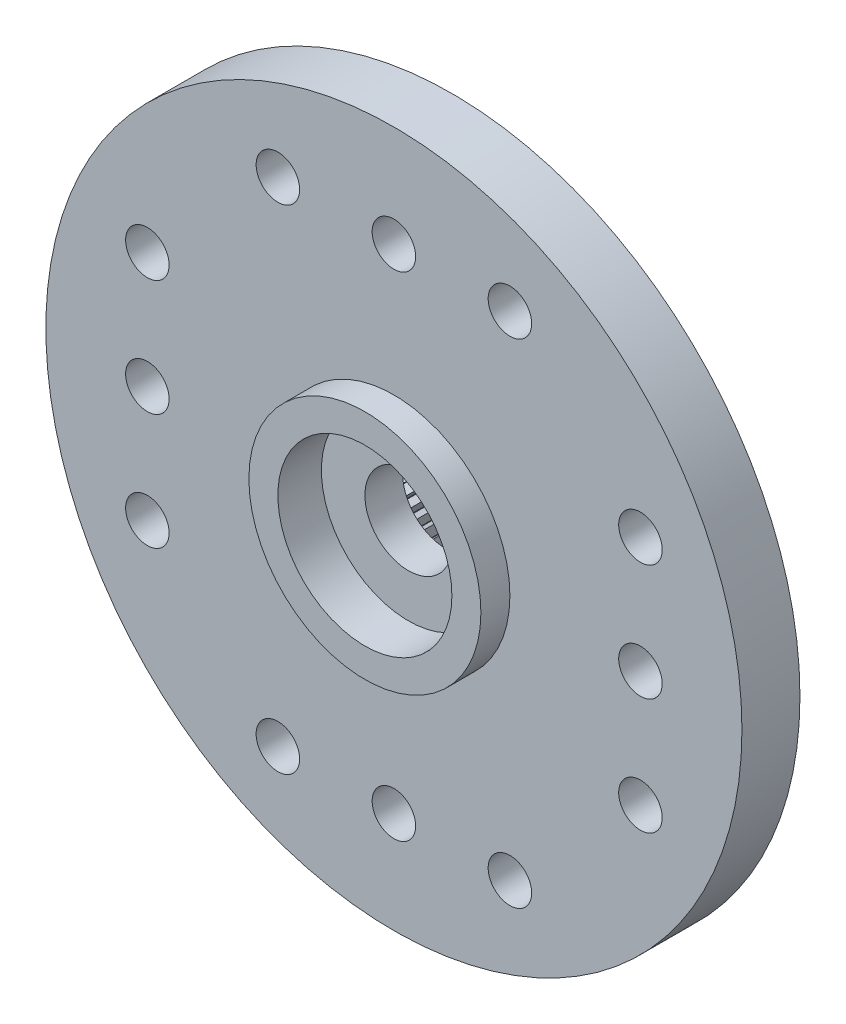
from build123d import *

# Parameters (mm, degrees)
ESQUISSE1_R                     = 4.5
BOSS_EXTRU_1_DEPTH              = 3.5
ESQUISSE2_R                     = 12
BOSS_EXTRU_2_DEPTH              = 2
ESQUISSE5_R                     = 4
BOSS_EXTRU_3_DEPTH              = 1
DIAM_TRE_DU_PER_AGE_3_0_3_2_D   = 3
ESQUISSE8_R                     = 3
ENL_V_MAT_EXTRU_1_DEPTH         = 1.5
ENL_V_MAT_EXTRU_2_DEPTH         = 3.7
DIAM_TRE_DU_PER_AGE_1_5_1_5_1_D = 1.5
R_P_TITION_CIRCULAIRE1_COUNT    = 4


with BuildPart() as part:
    # Esquisse1 → Boss.-Extru.1 (new body)
    with BuildSketch(Plane.XY):
        Circle(ESQUISSE1_R)
    extrude(amount=BOSS_EXTRU_1_DEPTH)

    # Esquisse2 → Boss.-Extru.2 (add)
    with BuildSketch(Plane.XY.offset(3.5)):
        Circle(ESQUISSE2_R)
    extrude(amount=BOSS_EXTRU_2_DEPTH)

    # Esquisse5 → Boss.-Extru.3 (add)
    with BuildSketch(Plane.XY.offset(5.5)):
        Circle(ESQUISSE5_R)
    extrude(amount=BOSS_EXTRU_3_DEPTH)

    # Diamètre du perçage Ø3.0 (3)2 (through all)
    with Locations(Plane.XY.offset(6.5)):
        with Locations((0, 0)):
            Hole(DIAM_TRE_DU_PER_AGE_3_0_3_2_D / 2)

    # Esquisse8 → Enlèv. mat.-Extru.1 (cut)
    with BuildSketch(Plane.XY.offset(6.5)):
        Circle(ESQUISSE8_R)
    extrude(amount=-ENL_V_MAT_EXTRU_1_DEPTH, mode=Mode.SUBTRACT)

    # Esquisse9 → Enlèv. mat.-Extru.2 (cut)
    with BuildSketch(Plane(origin=(0, 0, 0), x_dir=(-1, 0, 0), z_dir=(0, 0, -1))):
        with BuildLine():
            Line((0, 2.5), (0.180017522, 2.994594078))
            ThreePointArc((0.180017522, 2.994594078), (0.188371559, 2.994080185), (0.196724129, 2.993542987))
            Line((0.196724129, 2.993542987), (0.313333084, 2.480286753))
            Line((0.313333084, 2.480286753), (0.553920189, 2.948418631))
            ThreePointArc((0.553920189, 2.948418631), (0.562143944, 2.946861752), (0.570363322, 2.945281936))
            Line((0.570363322, 2.945281936), (0.621724718, 2.421457903))
            Line((0.621724718, 2.421457903), (0.919087204, 2.855744861))
            ThreePointArc((0.919087204, 2.855744861), (0.927050983, 2.853169549), (0.935007546, 2.850572028))
            Line((0.935007546, 2.850572028), (0.920311382, 2.324441215))
            Line((0.920311382, 2.324441215), (1.269759665, 2.718034289))
            ThreePointArc((1.269759665, 2.718034289), (1.277337875, 2.714481157), (1.284906142, 2.710906897))
            Line((1.284906142, 2.710906897), (1.204384185, 2.1907667))
            Line((1.204384185, 2.1907667), (1.600407257, 2.537458692))
            ThreePointArc((1.600407257, 2.537458692), (1.607480385, 2.532983777), (1.614541001, 2.528489145))
            Line((1.614541001, 2.528489145), (1.469463131, 2.022542486))
            Line((1.469463131, 2.022542486), (1.905815471, 2.316865855))
            ThreePointArc((1.905815471, 2.316865855), (1.912271969, 2.311539728), (1.918713583, 2.306195609))
            Line((1.918713583, 2.306195609), (1.711367765, 1.822421569))
            Line((1.711367765, 1.822421569), (2.181167836, 2.059734661))
            ThreePointArc((2.181167836, 2.059734661), (2.186905882, 2.053641318), (2.192626906, 2.04753199))
            Line((2.192626906, 2.04753199), (1.926283107, 1.593559974))
            Line((1.926283107, 1.593559974), (2.422121881, 1.77012022))
            ThreePointArc((2.422121881, 1.77012022), (2.427050983, 1.763355757), (2.431961193, 1.756577568))
            Line((2.431961193, 1.756577568), (2.110819814, 1.339566987))
            Line((2.110819814, 1.339566987), (2.624877618, 1.452589926))
            ThreePointArc((2.624877618, 1.452589926), (2.62892004, 1.445261022), (2.632942, 1.437920869))
            Line((2.632942, 1.437920869), (2.262067631, 1.064448229))
            Line((2.262067631, 1.064448229), (2.786237466, 1.112151421))
            ThreePointArc((2.786237466, 1.112151421), (2.789329458, 1.104373658), (2.792399738, 1.096587299))
            Line((2.792399738, 1.096587299), (2.377641291, 0.772542486))
            Line((2.377641291, 0.772542486), (2.903656685, 0.754173624))
            ThreePointArc((2.903656685, 0.754173624), (2.905749483, 0.746069661), (2.907819664, 0.737959892))
            Line((2.907819664, 0.737959892), (2.455718127, 0.468453286))
            Line((2.455718127, 0.468453286), (2.975283504, 0.384302058))
            ThreePointArc((2.975283504, 0.384302058), (2.976344104, 0.375999701), (2.977381537, 0.367694417))
            Line((2.977381537, 0.367694417), (2.495066821, 0.156976299))
            Line((2.495066821, 0.156976299), (2.999988324, 0.008369819))
            ThreePointArc((2.999988324, 0.008369819), (3, 0), (2.999988324, -0.008369819))
            Line((2.999988324, -0.008369819), (2.495066821, -0.156976299))
            Line((2.495066821, -0.156976299), (2.977381537, -0.367694417))
            ThreePointArc((2.977381537, -0.367694417), (2.976344104, -0.375999701), (2.975283504, -0.384302058))
            Line((2.975283504, -0.384302058), (2.455718127, -0.468453286))
            Line((2.455718127, -0.468453286), (2.907819664, -0.737959892))
            ThreePointArc((2.907819664, -0.737959892), (2.905749483, -0.746069661), (2.903656685, -0.754173624))
            Line((2.903656685, -0.754173624), (2.377641291, -0.772542486))
            Line((2.377641291, -0.772542486), (2.792399738, -1.096587299))
            ThreePointArc((2.792399738, -1.096587299), (2.789329458, -1.104373658), (2.786237466, -1.112151421))
            Line((2.786237466, -1.112151421), (2.262067631, -1.064448229))
            Line((2.262067631, -1.064448229), (2.632942, -1.437920869))
            ThreePointArc((2.632942, -1.437920869), (2.62892004, -1.445261022), (2.624877618, -1.452589926))
            Line((2.624877618, -1.452589926), (2.110819814, -1.339566987))
            Line((2.110819814, -1.339566987), (2.431961193, -1.756577568))
            ThreePointArc((2.431961193, -1.756577568), (2.427050983, -1.763355757), (2.422121881, -1.77012022))
            Line((2.422121881, -1.77012022), (1.926283107, -1.593559974))
            Line((1.926283107, -1.593559974), (2.192626906, -2.04753199))
            ThreePointArc((2.192626906, -2.04753199), (2.186905882, -2.053641318), (2.181167836, -2.059734661))
            Line((2.181167836, -2.059734661), (1.711367765, -1.822421569))
            Line((1.711367765, -1.822421569), (1.918713583, -2.306195609))
            ThreePointArc((1.918713583, -2.306195609), (1.912271969, -2.311539728), (1.905815471, -2.316865855))
            Line((1.905815471, -2.316865855), (1.469463131, -2.022542486))
            Line((1.469463131, -2.022542486), (1.614541001, -2.528489145))
            ThreePointArc((1.614541001, -2.528489145), (1.607480385, -2.532983777), (1.600407257, -2.537458692))
            Line((1.600407257, -2.537458692), (1.204384185, -2.1907667))
            Line((1.204384185, -2.1907667), (1.284906142, -2.710906897))
            ThreePointArc((1.284906142, -2.710906897), (1.277337875, -2.714481157), (1.269759665, -2.718034289))
            Line((1.269759665, -2.718034289), (0.920311382, -2.324441215))
            Line((0.920311382, -2.324441215), (0.935007546, -2.850572028))
            ThreePointArc((0.935007546, -2.850572028), (0.927050983, -2.853169549), (0.919087204, -2.855744861))
            Line((0.919087204, -2.855744861), (0.621724718, -2.421457903))
            Line((0.621724718, -2.421457903), (0.570363322, -2.945281936))
            ThreePointArc((0.570363322, -2.945281936), (0.562143944, -2.946861752), (0.553920189, -2.948418631))
            Line((0.553920189, -2.948418631), (0.313333084, -2.480286753))
            Line((0.313333084, -2.480286753), (0.196724129, -2.993542987))
            ThreePointArc((0.196724129, -2.993542987), (0.188371559, -2.994080185), (0.180017522, -2.994594078))
            Line((0.180017522, -2.994594078), (0, -2.5))
            Line((0, -2.5), (-0.180017522, -2.994594078))
            ThreePointArc((-0.180017522, -2.994594078), (-0.188371559, -2.994080185), (-0.196724129, -2.993542987))
            Line((-0.196724129, -2.993542987), (-0.313333084, -2.480286753))
            Line((-0.313333084, -2.480286753), (-0.553920189, -2.948418631))
            ThreePointArc((-0.553920189, -2.948418631), (-0.562143944, -2.946861752), (-0.570363322, -2.945281936))
            Line((-0.570363322, -2.945281936), (-0.621724718, -2.421457903))
            Line((-0.621724718, -2.421457903), (-0.919087204, -2.855744861))
            ThreePointArc((-0.919087204, -2.855744861), (-0.927050983, -2.853169549), (-0.935007546, -2.850572028))
            Line((-0.935007546, -2.850572028), (-0.920311382, -2.324441215))
            Line((-0.920311382, -2.324441215), (-1.269759665, -2.718034289))
            ThreePointArc((-1.269759665, -2.718034289), (-1.277337875, -2.714481157), (-1.284906142, -2.710906897))
            Line((-1.284906142, -2.710906897), (-1.204384185, -2.1907667))
            Line((-1.204384185, -2.1907667), (-1.600407257, -2.537458692))
            ThreePointArc((-1.600407257, -2.537458692), (-1.607480385, -2.532983777), (-1.614541001, -2.528489145))
            Line((-1.614541001, -2.528489145), (-1.469463131, -2.022542486))
            Line((-1.469463131, -2.022542486), (-1.905815471, -2.316865855))
            ThreePointArc((-1.905815471, -2.316865855), (-1.912271969, -2.311539728), (-1.918713583, -2.306195609))
            Line((-1.918713583, -2.306195609), (-1.711367765, -1.822421569))
            Line((-1.711367765, -1.822421569), (-2.181167836, -2.059734661))
            ThreePointArc((-2.181167836, -2.059734661), (-2.186905882, -2.053641318), (-2.192626906, -2.04753199))
            Line((-2.192626906, -2.04753199), (-1.926283107, -1.593559974))
            Line((-1.926283107, -1.593559974), (-2.422121881, -1.77012022))
            ThreePointArc((-2.422121881, -1.77012022), (-2.427050983, -1.763355757), (-2.431961193, -1.756577568))
            Line((-2.431961193, -1.756577568), (-2.110819814, -1.339566987))
            Line((-2.110819814, -1.339566987), (-2.624877618, -1.452589926))
            ThreePointArc((-2.624877618, -1.452589926), (-2.62892004, -1.445261022), (-2.632942, -1.437920869))
            Line((-2.632942, -1.437920869), (-2.262067631, -1.064448229))
            Line((-2.262067631, -1.064448229), (-2.786237466, -1.112151421))
            ThreePointArc((-2.786237466, -1.112151421), (-2.789329458, -1.104373658), (-2.792399738, -1.096587299))
            Line((-2.792399738, -1.096587299), (-2.377641291, -0.772542486))
            Line((-2.377641291, -0.772542486), (-2.903656685, -0.754173624))
            ThreePointArc((-2.903656685, -0.754173624), (-2.905749483, -0.746069661), (-2.907819664, -0.737959892))
            Line((-2.907819664, -0.737959892), (-2.455718127, -0.468453286))
            Line((-2.455718127, -0.468453286), (-2.975283504, -0.384302058))
            ThreePointArc((-2.975283504, -0.384302058), (-2.976344104, -0.375999701), (-2.977381537, -0.367694417))
            Line((-2.977381537, -0.367694417), (-2.495066821, -0.156976299))
            Line((-2.495066821, -0.156976299), (-2.999988324, -0.008369819))
            ThreePointArc((-2.999988324, -0.008369819), (-3, 0), (-2.999988324, 0.008369819))
            Line((-2.999988324, 0.008369819), (-2.495066821, 0.156976299))
            Line((-2.495066821, 0.156976299), (-2.977381537, 0.367694417))
            ThreePointArc((-2.977381537, 0.367694417), (-2.976344104, 0.375999701), (-2.975283504, 0.384302058))
            Line((-2.975283504, 0.384302058), (-2.455718127, 0.468453286))
            Line((-2.455718127, 0.468453286), (-2.907819664, 0.737959892))
            ThreePointArc((-2.907819664, 0.737959892), (-2.905749483, 0.746069661), (-2.903656685, 0.754173624))
            Line((-2.903656685, 0.754173624), (-2.377641291, 0.772542486))
            Line((-2.377641291, 0.772542486), (-2.792399738, 1.096587299))
            ThreePointArc((-2.792399738, 1.096587299), (-2.789329458, 1.104373658), (-2.786237466, 1.112151421))
            Line((-2.786237466, 1.112151421), (-2.262067631, 1.064448229))
            Line((-2.262067631, 1.064448229), (-2.632942, 1.437920869))
            ThreePointArc((-2.632942, 1.437920869), (-2.62892004, 1.445261022), (-2.624877618, 1.452589926))
            Line((-2.624877618, 1.452589926), (-2.110819814, 1.339566987))
            Line((-2.110819814, 1.339566987), (-2.431961193, 1.756577568))
            ThreePointArc((-2.431961193, 1.756577568), (-2.427050983, 1.763355757), (-2.422121881, 1.77012022))
            Line((-2.422121881, 1.77012022), (-1.926283107, 1.593559974))
            Line((-1.926283107, 1.593559974), (-2.192626906, 2.04753199))
            ThreePointArc((-2.192626906, 2.04753199), (-2.186905882, 2.053641318), (-2.181167836, 2.059734661))
            Line((-2.181167836, 2.059734661), (-1.711367765, 1.822421569))
            Line((-1.711367765, 1.822421569), (-1.918713583, 2.306195609))
            ThreePointArc((-1.918713583, 2.306195609), (-1.912271969, 2.311539728), (-1.905815471, 2.316865855))
            Line((-1.905815471, 2.316865855), (-1.469463131, 2.022542486))
            Line((-1.469463131, 2.022542486), (-1.614541001, 2.528489145))
            ThreePointArc((-1.614541001, 2.528489145), (-1.607480385, 2.532983777), (-1.600407257, 2.537458692))
            Line((-1.600407257, 2.537458692), (-1.204384185, 2.1907667))
            Line((-1.204384185, 2.1907667), (-1.284906142, 2.710906897))
            ThreePointArc((-1.284906142, 2.710906897), (-1.277337875, 2.714481157), (-1.269759665, 2.718034289))
            Line((-1.269759665, 2.718034289), (-0.920311382, 2.324441215))
            Line((-0.920311382, 2.324441215), (-0.935007546, 2.850572028))
            ThreePointArc((-0.935007546, 2.850572028), (-0.927050983, 2.853169549), (-0.919087204, 2.855744861))
            Line((-0.919087204, 2.855744861), (-0.621724718, 2.421457903))
            Line((-0.621724718, 2.421457903), (-0.570363322, 2.945281936))
            ThreePointArc((-0.570363322, 2.945281936), (-0.562143944, 2.946861752), (-0.553920189, 2.948418631))
            Line((-0.553920189, 2.948418631), (-0.313333084, 2.480286753))
            Line((-0.313333084, 2.480286753), (-0.196724129, 2.993542987))
            ThreePointArc((-0.196724129, 2.993542987), (-0.188371559, 2.994080185), (-0.180017522, 2.994594078))
            Line((-0.180017522, 2.994594078), (0, 2.5))
        make_face()
    extrude(amount=-ENL_V_MAT_EXTRU_2_DEPTH, mode=Mode.SUBTRACT)

    # Diamètre du perçage Ø1.5 (1.5)1 (through all)
    with Locations(Plane.XY.offset(5.5)):
        with Locations((-8.5, 0), (-8.5, 4), (-8.5, -4)):
            diam_tre_du_per_age_1_5_1_5_1 = Hole(DIAM_TRE_DU_PER_AGE_1_5_1_5_1_D / 2)

    # Répétition circulaire1: Diamètre du perçage Ø1.5 (1.5)1 ×4 about axis
    r_p_tition_circulaire1_axis = Axis((0, 0, 0), (0, 0, 1))
    for i in range(1, R_P_TITION_CIRCULAIRE1_COUNT):
        add(diam_tre_du_per_age_1_5_1_5_1.rotate(r_p_tition_circulaire1_axis, i * 360 / R_P_TITION_CIRCULAIRE1_COUNT), mode=Mode.SUBTRACT)


solid = part.part
